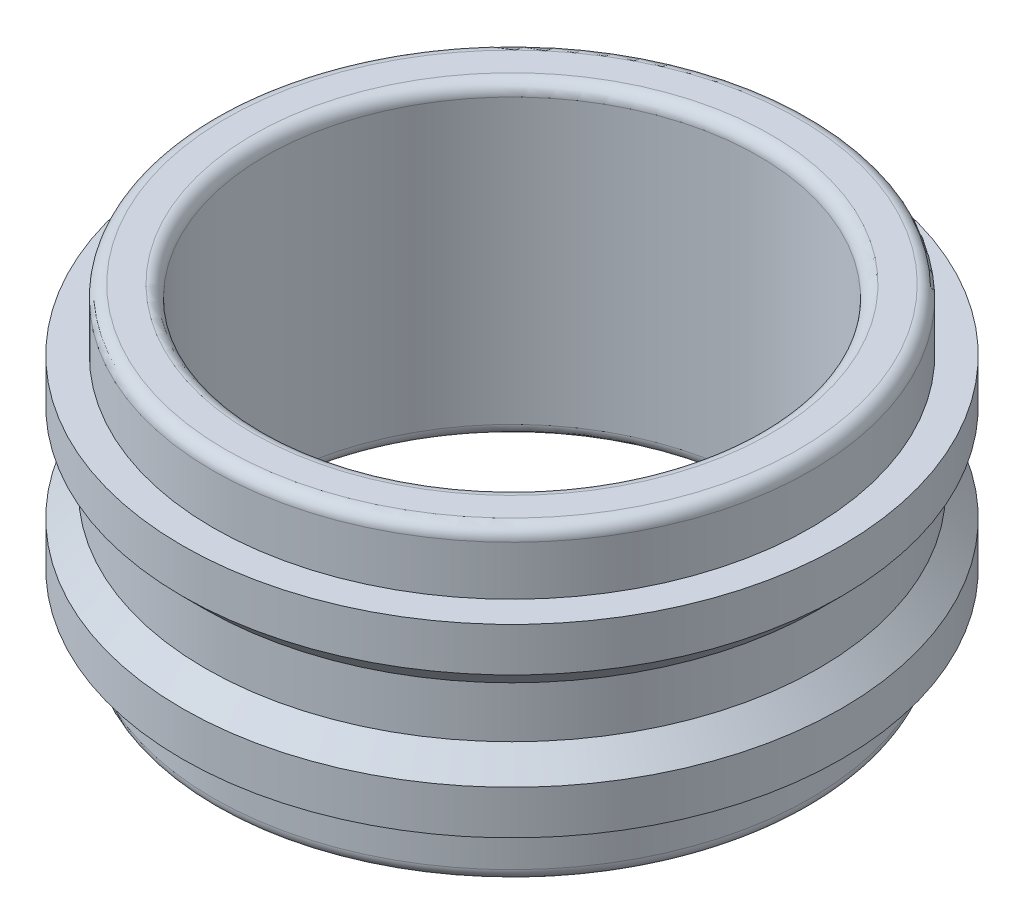
from build123d import *

# Parameters (mm, degrees)
IZIM1_R                     = 5.35
IZIM1_R_2                   = 4
Y_KSEKLIK_EKSTR_ZYON1_DEPTH = 5
IZIM4_R                     = 5.35
IZIM4_R_2                   = 4.85
KES_EKSTR_ZYON1_DEPTH       = 1
L_O_ALTMA1_COUNT            = 2
L_O_ALTMA1_PITCH            = 4
RADYUS1_R                   = 0.2


with BuildPart() as part:
    # Çizim1 → Yükseklik-Ekstrüzyon1 (new body)
    with BuildSketch(Plane(origin=(0, 0, 0), x_dir=(1, 0, 0), z_dir=(0, 1, 0))):
        Circle(IZIM1_R)
        Circle(IZIM1_R_2, mode=Mode.SUBTRACT)
    extrude(amount=Y_KSEKLIK_EKSTR_ZYON1_DEPTH)

    # Çizim4 → Kes-Ekstrüzyon1 (cut)
    with BuildSketch(Plane(origin=(0, 5, 0), x_dir=(1, 0, 0), z_dir=(0, 1, 0))):
        Circle(IZIM4_R)
        Circle(IZIM4_R_2, mode=Mode.SUBTRACT)
    kes_ekstr_zyon1 = extrude(amount=-KES_EKSTR_ZYON1_DEPTH, mode=Mode.SUBTRACT)

    # LÇoğaltma1: Kes-Ekstrüzyon1 ×2
    with Locations(*[(0, -i * L_O_ALTMA1_PITCH, 0) for i in range(1, L_O_ALTMA1_COUNT)]):
        add(kes_ekstr_zyon1, mode=Mode.SUBTRACT)

    # Çizim6 → Kes-Döndür1 (revolve, cut)
    with BuildSketch(Plane.XY):
        Polygon((-5.560786438, 3.5), (-4.975, 2.914213562), (-4.975, 2.085786438), (-5.560786438, 1.5), align=None)
    revolve(axis=Axis((0, 0, 0), (0, 1, 0)), mode=Mode.SUBTRACT)

    # Radyus1
    radyus1_edges = [part.edges().sort_by_distance(p)[0] for p in [
        (-4.85, 5, 0),
        (-4.85, 0, 0),
        (-4, 0, 0),
        (-4, 5, 0),
    ]]
    fillet(radyus1_edges, radius=RADYUS1_R)


solid = part.part
